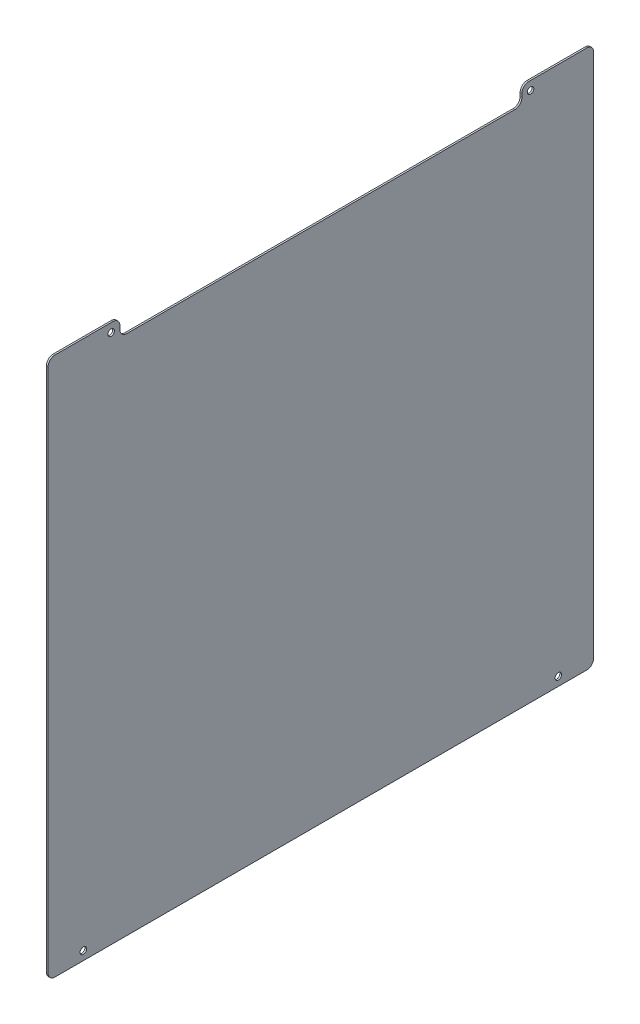
from build123d import *

# Parameters (mm, degrees)
BOSS_EXTRUDE1_DEPTH      = 1.5875
A_0_234_DIAMETER_HOLE1_D = 5.9436


with BuildPart() as part:
    # Sketch1 → Boss-Extrude1 (new body)
    with BuildSketch(Plane(origin=(0, 0, 0), x_dir=(0, 0, -1), z_dir=(1, 0, 0))):
        with BuildLine():
            Line((438.6326, 491.49), (491.49, 491.49))
            ThreePointArc((491.49, 491.49), (495.980128061, 489.630128061), (497.84, 485.14))
            Line((497.84, 485.14), (497.84, 6.35))
            ThreePointArc((497.84, 6.35), (495.980128061, 1.859871939), (491.49, 0))
            Line((491.49, 0), (6.35, 0))
            ThreePointArc((6.35, 0), (1.859871939, 1.859871939), (0, 6.35))
            Line((0, 6.35), (0, 485.14))
            ThreePointArc((0, 485.14), (1.859871939, 489.630128061), (6.35, 491.49))
            Line((6.35, 491.49), (59.2074, 491.49))
            ThreePointArc((59.2074, 491.49), (63.697528061, 489.630128061), (65.5574, 485.14))
            Line((65.5574, 485.14), (65.5574, 481.965))
            ThreePointArc((65.5574, 481.965), (67.417271939, 477.474871939), (71.9074, 475.615))
            Line((71.9074, 475.615), (425.9326, 475.615))
            ThreePointArc((425.9326, 475.615), (430.422728061, 477.474871939), (432.2826, 481.965))
            Line((432.2826, 481.965), (432.2826, 485.14))
            ThreePointArc((432.2826, 485.14), (434.142471939, 489.630128061), (438.6326, 491.49))
        make_face()
    extrude(amount=-BOSS_EXTRUDE1_DEPTH)

    # A (0.234) Diameter Hole1 (through all)
    with Locations(Plane(origin=(1.02362, -1353.361752646, -2205.813131805), x_dir=(0, 0, -1), z_dir=(1, 0, 0))):
        with Locations((-2173.593231805, 1361.299252646), (-1740.193031805, 1361.29924771), (-1765.593031805, 1836.91424771), (-2148.193231805, 1836.91424771)):
            Hole(A_0_234_DIAMETER_HOLE1_D / 2)


solid = part.part
